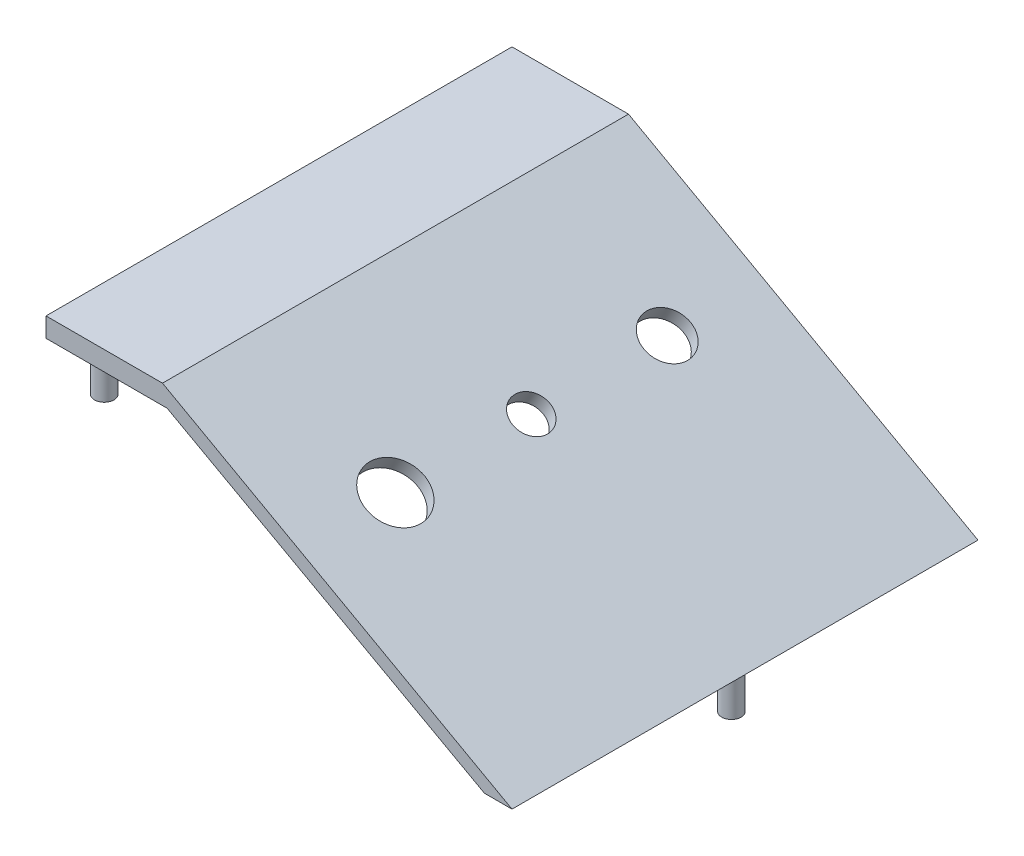
from build123d import *

# Parameters (mm, degrees)
SKETCH1_W           = 152.4
SKETCH1_H           = 76.2
BOSS_EXTRUDE1_DEPTH = 152.4
CUT_EXTRUDE1_DEPTH  = 152.4
CUT_EXTRUDE4_DEPTH  = 152.4
SKETCH6_R           = 9.525
SKETCH6_R_2         = 6.096
SKETCH6_R_3         = 7.62
CUT_EXTRUDE5_DEPTH  = 25.4
SKETCH7_R           = 3.175
BOSS_EXTRUDE2_DEPTH = 12.7
SKETCH8_W           = 9.01836237
SKETCH8_H           = 12.7
CUT_EXTRUDE6_DEPTH  = 152.4
SKETCH9_R           = 3.175
BOSS_EXTRUDE3_DEPTH = 12.7


with BuildPart() as part:
    # Sketch1 → Boss-Extrude1 (new body)
    with BuildSketch(Plane.XY):
        with Locations((76.2, 38.1)):
            Rectangle(SKETCH1_W, SKETCH1_H)
    extrude(amount=BOSS_EXTRUDE1_DEPTH)

    # Sketch2 → Cut-Extrude1 (cut)
    with BuildSketch(Plane.XY.offset(152.4)):
        Polygon((152.4, 76.2), (38.1, 76.2), (152.4, 12.7), align=None)
    extrude(amount=-CUT_EXTRUDE1_DEPTH, mode=Mode.SUBTRACT)

    # Sketch4 → Cut-Extrude4 (cut)
    with BuildSketch(Plane.XY.offset(152.4)):
        Polygon((39.625354208, 69.85), (146.05, 11.230239284), (146.05, 0), (0, 0), (0, 69.85), align=None)
    extrude(amount=-CUT_EXTRUDE4_DEPTH, mode=Mode.SUBTRACT)

    # Sketch6 → Cut-Extrude5 (cut)
    with BuildSketch(Plane(origin=(41.33490566, 74.402830189, 0), x_dir=(0.874157276, -0.485642931, 0), z_dir=(0.485642931, 0.874157276, 0))):
        with Locations((47.099400864, -120.65)):
            Circle(SKETCH6_R)
        with Locations((47.099400864, -76.2)):
            Circle(SKETCH6_R_2)
        with Locations((47.099400864, -31.75)):
            Circle(SKETCH6_R_3)
    extrude(amount=-CUT_EXTRUDE5_DEPTH, mode=Mode.SUBTRACT)

    # Sketch7 → Boss-Extrude2 (add)
    with BuildSketch(Plane.XZ.offset(-69.85)):
        with Locations((12.7, 6.35)):
            Circle(SKETCH7_R)
        with Locations((12.7, 146.05)):
            Circle(SKETCH7_R)
    extrude(amount=BOSS_EXTRUDE2_DEPTH)

    # Sketch8 → Cut-Extrude6 (cut)
    with BuildSketch(Plane.XY.offset(152.4)):
        with Locations((147.890818815, 6.35)):
            Rectangle(SKETCH8_W, SKETCH8_H)
    extrude(amount=-CUT_EXTRUDE6_DEPTH, mode=Mode.SUBTRACT)

    # Sketch9 → Boss-Extrude3 (add)
    with BuildSketch(Plane.XZ.offset(-12.7)):
        with Locations((147.955, 76.2)):
            Circle(SKETCH9_R)
    extrude(amount=BOSS_EXTRUDE3_DEPTH)


solid = part.part
